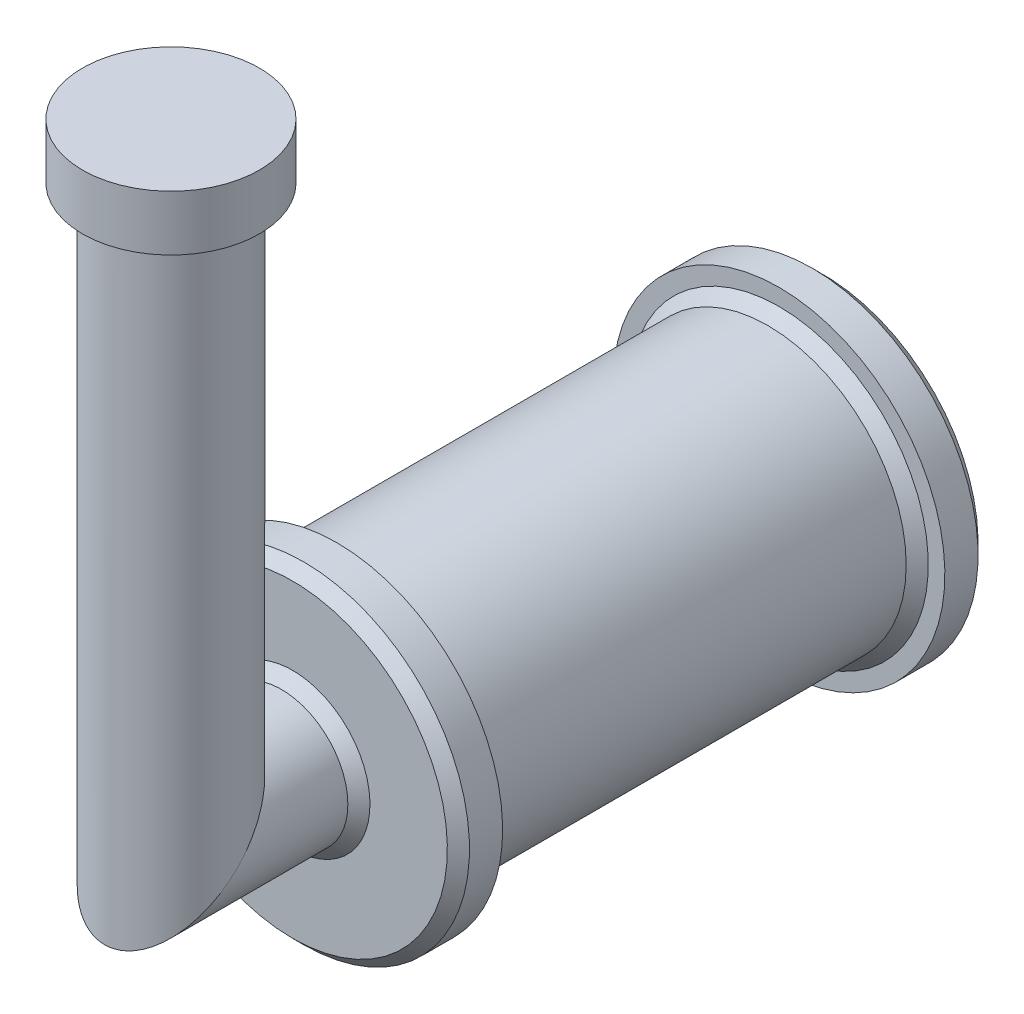
from build123d import *

# Parameters (mm, degrees)
SKETCH2_R           = 75
SKETCH3_R           = 100
BOSS_EXTRUDE1_DEPTH = 62.5
CHAMFER1_SIZE       = 12.5


with BuildPart() as part:
    # Sweep1: sweep along a path in Sketch1
    with BuildLine(Plane(origin=(0, 0, 0), x_dir=(0, 0, -1), z_dir=(1, 0, 0))) as sweep1_path:
        Line((0, 695.970875), (0, 0))
        Line((0, 0), (737.5, 0))
    # Sketch2 → Sweep1 (sweep)
    with BuildSketch(Plane(origin=(0, 695.970875, 0), x_dir=(1, 0, 0), z_dir=(0, 1, 0))):
        Circle(SKETCH2_R)
    sweep(path=sweep1_path.line, transition=Transition.RIGHT)

    # Sketch3 → Boss-Extrude1 (add)
    with BuildSketch(Plane(origin=(0, 695.970875, 0), x_dir=(1, 0, 0), z_dir=(0, 1, 0))):
        Circle(SKETCH3_R)
    extrude(amount=-BOSS_EXTRUDE1_DEPTH)

    # Sketch4 → Revolve1 (revolve)
    with BuildSketch(Plane(origin=(0, 0, 0), x_dir=(0, 0, -1), z_dir=(1, 0, 0))):
        Polygon((137.5, 75), (137.5, 187.5), (187.5, 187.5), (187.5, 156.25), (687.5, 156.25), (687.5, 187.5), (737.5, 187.5), (737.5, 75), align=None)
    revolve(axis=Axis((0, 0, -737.5), (0, 0, 1)))

    # Chamfer1
    chamfer1_edges = [part.edges().sort_by_distance(p)[0] for p in [
        (-75, 0, -137.5),
        (0, -187.5, -137.5),
        (0, -156.25, -187.5),
        (0, -156.25, -687.5),
        (0, -187.5, -737.5),
    ]]
    chamfer(chamfer1_edges, length=CHAMFER1_SIZE)


solid = part.part
